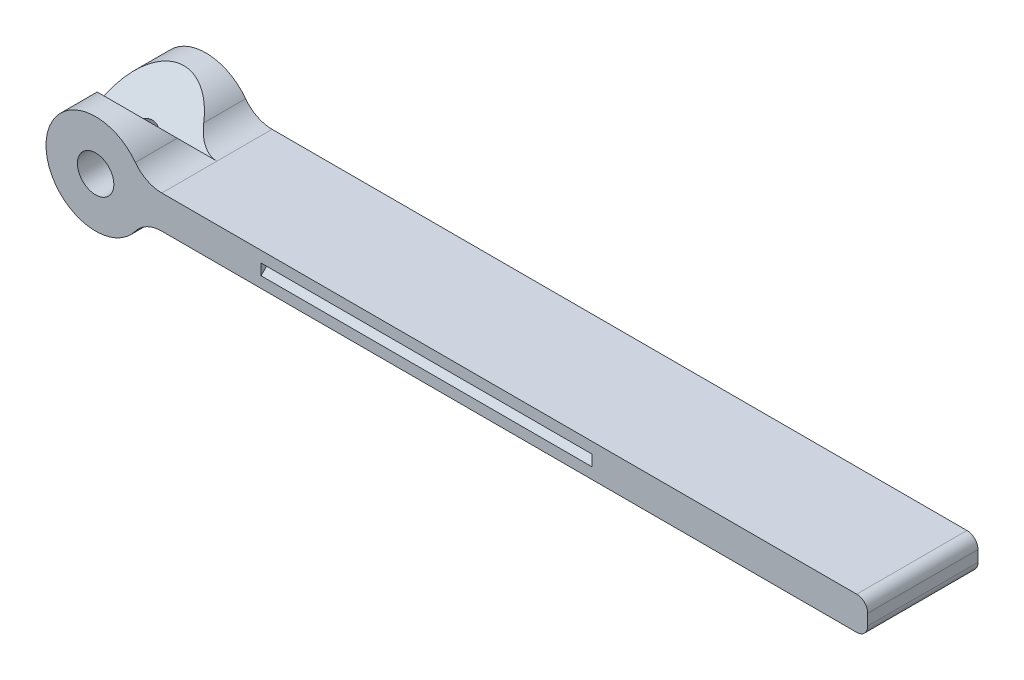
from build123d import *

# Parameters (mm, degrees)
SKETCH1_R           = 1.65
BOSS_EXTRUDE1_DEPTH = 10
CUT_EXTRUDE1_DEPTH  = 29
CUT_EXTRUDE2_START  = -25
CUT_EXTRUDE2_DEPTH  = 30


with BuildPart() as part:
    # Sketch1 → Boss-Extrude1 (new body)
    with BuildSketch(Plane.XY):
        with BuildLine():
            Line((52.062696878, 9.140164993), (-10.937303122, 9.140164993))
            ThreePointArc((-10.937303122, 9.140164993), (-12.278943909, 8.823446566), (-13.337303122, 7.940164993))
            ThreePointArc((-13.337303122, 7.940164993), (-21.437303122, 10.640164993), (-13.337303122, 13.340164993))
            ThreePointArc((-13.337303122, 13.340164993), (-12.278943909, 12.45688342), (-10.937303122, 12.140164993))
            Line((-10.937303122, 12.140164993), (52.062696878, 12.140164993))
            ThreePointArc((52.062696878, 12.140164993), (52.769803659, 11.847271774), (53.062696878, 11.140164993))
            Line((53.062696878, 11.140164993), (53.062696878, 10.140164993))
            ThreePointArc((53.062696878, 10.140164993), (52.769803659, 9.433058211), (52.062696878, 9.140164993))
        make_face()
        with Locations((-16.937303122, 10.640164993)):
            Circle(SKETCH1_R, mode=Mode.SUBTRACT)
    extrude(amount=BOSS_EXTRUDE1_DEPTH)

    # Sketch7 → Cut-Extrude1 (cut)
    with BuildSketch(Plane(origin=(0, 0, 0), x_dir=(0, 0, -1), z_dir=(1, 0, 0))):
        Polygon((-8, 15.140164993), (-5, 12.140164993), (-2, 15.140164993), align=None)
    extrude(amount=-CUT_EXTRUDE1_DEPTH, mode=Mode.SUBTRACT)

    # Sketch8 → Cut-Extrude2 (cut)
    with BuildSketch(Plane(origin=(53.062696878, 0, 0), x_dir=(0, 0, -1), z_dir=(1, 0, 0)).offset(CUT_EXTRUDE2_START)):
        Polygon((0, 11.140164993), (-0.5, 10.640164993), (0, 10.140164993), align=None)
    cut_extrude2 = extrude(amount=-CUT_EXTRUDE2_DEPTH, mode=Mode.SUBTRACT)

    # Mirror1: Cut-Extrude2 across plane
    add(cut_extrude2.mirror(Plane(origin=(0, 0, 5), x_dir=(1, 0, 0), z_dir=(0, 0, -1))), mode=Mode.SUBTRACT)


solid = part.part
